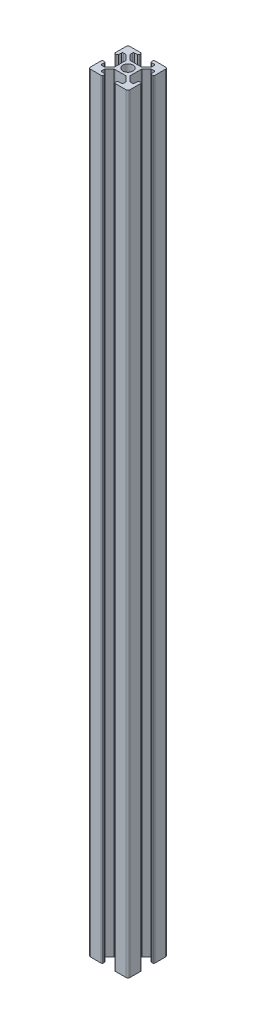
from build123d import *

# Parameters (mm, degrees)
SKETCH1_R           = 2.6
BOSS_EXTRUDE1_DEPTH = 390


with BuildPart() as part:
    # Sketch1 → Boss-Extrude1 (new body)
    with BuildSketch(Plane(origin=(0, 195, 0), x_dir=(1, 0, 0), z_dir=(0, 1, 0))):
        with BuildLine():
            Line((-3.1, 8.85), (-3.1, 9.5))
            ThreePointArc((-3.1, 9.5), (-3.246446609, 9.853553391), (-3.6, 10))
            Line((-3.6, 10), (-9, 10))
            ThreePointArc((-9, 10), (-9.707106781, 9.707106781), (-10, 9))
            Line((-10, 9), (-10, 3.6))
            ThreePointArc((-10, 3.6), (-9.853553391, 3.246446609), (-9.5, 3.1))
            Line((-9.5, 3.1), (-8.85, 3.1))
            ThreePointArc((-8.85, 3.1), (-8.496446609, 3.246446609), (-8.35, 3.6))
            Line((-8.35, 3.6), (-8.35, 5))
            ThreePointArc((-8.35, 5), (-8.203553391, 5.353553391), (-7.85, 5.5))
            Line((-7.85, 5.5), (-6.626345597, 5.5))
            ThreePointArc((-6.626345597, 5.5), (-6.435003881, 5.461939766), (-6.272792206, 5.353553391))
            Line((-6.272792206, 5.353553391), (-4.046446609, 3.127207794))
            ThreePointArc((-4.046446609, 3.127207794), (-3.938060234, 2.964996119), (-3.9, 2.773654403))
            Line((-3.9, 2.773654403), (-3.9, -2.773654403))
            ThreePointArc((-3.9, -2.773654403), (-3.938060234, -2.964996119), (-4.046446609, -3.127207794))
            Line((-4.046446609, -3.127207794), (-6.272792206, -5.353553391))
            ThreePointArc((-6.272792206, -5.353553391), (-6.435003881, -5.461939766), (-6.626345597, -5.5))
            Line((-6.626345597, -5.5), (-7.85, -5.5))
            ThreePointArc((-7.85, -5.5), (-8.203553391, -5.353553391), (-8.35, -5))
            Line((-8.35, -5), (-8.35, -3.6))
            ThreePointArc((-8.35, -3.6), (-8.496446609, -3.246446609), (-8.85, -3.1))
            Line((-8.85, -3.1), (-9.5, -3.1))
            ThreePointArc((-9.5, -3.1), (-9.853553391, -3.246446609), (-10, -3.6))
            Line((-10, -3.6), (-10, -9))
            ThreePointArc((-10, -9), (-9.707106781, -9.707106781), (-9, -10))
            Line((-9, -10), (-3.6, -10))
            ThreePointArc((-3.6, -10), (-3.246446609, -9.853553391), (-3.1, -9.5))
            Line((-3.1, -9.5), (-3.1, -8.85))
            ThreePointArc((-3.1, -8.85), (-3.246446609, -8.496446609), (-3.6, -8.35))
            Line((-3.6, -8.35), (-5, -8.35))
            ThreePointArc((-5, -8.35), (-5.353553391, -8.203553391), (-5.5, -7.85))
            Line((-5.5, -7.85), (-5.5, -6.626345597))
            ThreePointArc((-5.5, -6.626345597), (-5.461939766, -6.435003881), (-5.353553391, -6.272792206))
            Line((-5.353553391, -6.272792206), (-3.127207794, -4.046446609))
            ThreePointArc((-3.127207794, -4.046446609), (-2.964996119, -3.938060234), (-2.773654403, -3.9))
            Line((-2.773654403, -3.9), (2.773654403, -3.9))
            ThreePointArc((2.773654403, -3.9), (2.964996119, -3.938060234), (3.127207794, -4.046446609))
            Line((3.127207794, -4.046446609), (5.353553391, -6.272792206))
            ThreePointArc((5.353553391, -6.272792206), (5.461939766, -6.435003881), (5.5, -6.626345597))
            Line((5.5, -6.626345597), (5.5, -7.85))
            ThreePointArc((5.5, -7.85), (5.353553391, -8.203553391), (5, -8.35))
            Line((5, -8.35), (3.6, -8.35))
            ThreePointArc((3.6, -8.35), (3.246446609, -8.496446609), (3.1, -8.85))
            Line((3.1, -8.85), (3.1, -9.5))
            ThreePointArc((3.1, -9.5), (3.246446609, -9.853553391), (3.6, -10))
            Line((3.6, -10), (9, -10))
            ThreePointArc((9, -10), (9.707106781, -9.707106781), (10, -9))
            Line((10, -9), (10, -3.6))
            ThreePointArc((10, -3.6), (9.853553391, -3.246446609), (9.5, -3.1))
            Line((9.5, -3.1), (8.85, -3.1))
            ThreePointArc((8.85, -3.1), (8.496446609, -3.246446609), (8.35, -3.6))
            Line((8.35, -3.6), (8.35, -5))
            ThreePointArc((8.35, -5), (8.203553391, -5.353553391), (7.85, -5.5))
            Line((7.85, -5.5), (6.626345597, -5.5))
            ThreePointArc((6.626345597, -5.5), (6.435003881, -5.461939766), (6.272792206, -5.353553391))
            Line((6.272792206, -5.353553391), (4.046446609, -3.127207794))
            ThreePointArc((4.046446609, -3.127207794), (3.938060234, -2.964996119), (3.9, -2.773654403))
            Line((3.9, -2.773654403), (3.9, 2.773654403))
            ThreePointArc((3.9, 2.773654403), (3.938060234, 2.964996119), (4.046446609, 3.127207794))
            Line((4.046446609, 3.127207794), (6.272792206, 5.353553391))
            ThreePointArc((6.272792206, 5.353553391), (6.435003881, 5.461939766), (6.626345597, 5.5))
            Line((6.626345597, 5.5), (7.85, 5.5))
            ThreePointArc((7.85, 5.5), (8.203553391, 5.353553391), (8.35, 5))
            Line((8.35, 5), (8.35, 3.6))
            ThreePointArc((8.35, 3.6), (8.496446609, 3.246446609), (8.85, 3.1))
            Line((8.85, 3.1), (9.5, 3.1))
            ThreePointArc((9.5, 3.1), (9.853553391, 3.246446609), (10, 3.6))
            Line((10, 3.6), (10, 9))
            ThreePointArc((10, 9), (9.707106781, 9.707106781), (9, 10))
            Line((9, 10), (3.6, 10))
            ThreePointArc((3.6, 10), (3.246446609, 9.853553391), (3.1, 9.5))
            Line((3.1, 9.5), (3.1, 8.85))
            ThreePointArc((3.1, 8.85), (3.246446609, 8.496446609), (3.6, 8.35))
            Line((3.6, 8.35), (5, 8.35))
            ThreePointArc((5, 8.35), (5.353553391, 8.203553391), (5.5, 7.85))
            Line((5.5, 7.85), (5.5, 6.626345597))
            ThreePointArc((5.5, 6.626345597), (5.461939766, 6.435003881), (5.353553391, 6.272792206))
            Line((5.353553391, 6.272792206), (3.127207794, 4.046446609))
            ThreePointArc((3.127207794, 4.046446609), (2.964996119, 3.938060234), (2.773654403, 3.9))
            Line((2.773654403, 3.9), (-2.773654403, 3.9))
            ThreePointArc((-2.773654403, 3.9), (-2.964996119, 3.938060234), (-3.127207794, 4.046446609))
            Line((-3.127207794, 4.046446609), (-5.5, 6.419238816))
            Line((-5.5, 6.419238816), (-5.5, 7.85))
            ThreePointArc((-5.5, 7.85), (-5.353553391, 8.203553391), (-5, 8.35))
            Line((-5, 8.35), (-3.6, 8.35))
            ThreePointArc((-3.6, 8.35), (-3.246446609, 8.496446609), (-3.1, 8.85))
        make_face()
        Circle(SKETCH1_R, mode=Mode.SUBTRACT)
    extrude(amount=-BOSS_EXTRUDE1_DEPTH)


solid = part.part
